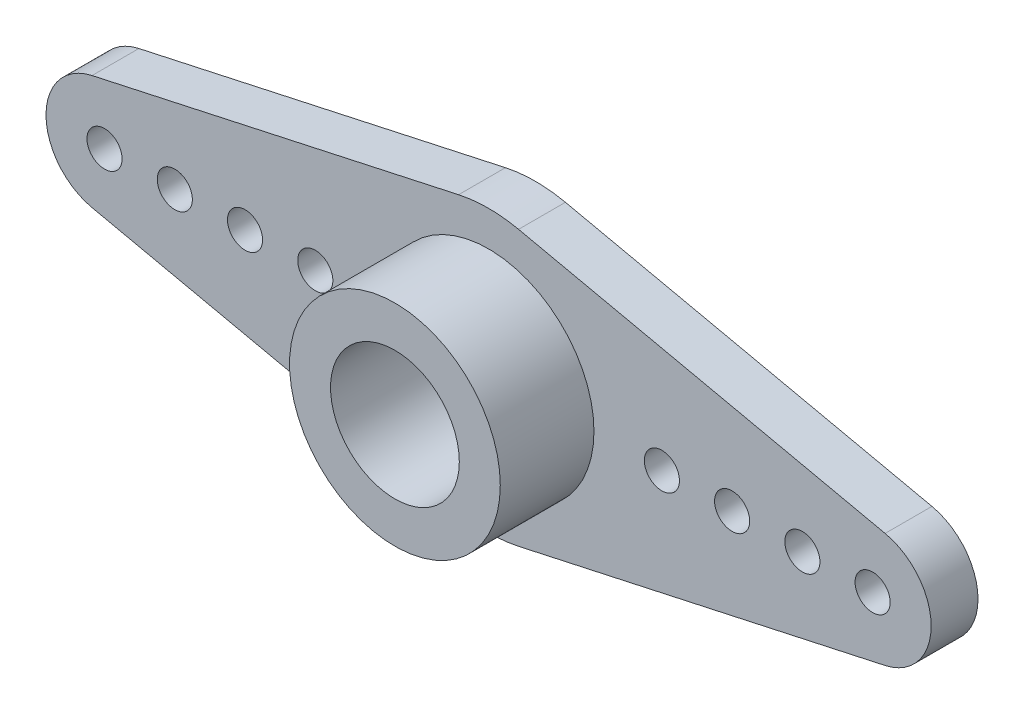
from build123d import *

# Parameters (mm, degrees)
IZIM1_R                     = 1.5
IZIM1_R_2                   = 0.75
Y_KSEKLIK_EKSTR_ZYON1_DEPTH = 2
IZIM2_R                     = 4.5
IZIM2_R_2                   = 2.75
Y_KSEKLIK_EKSTR_ZYON2_DEPTH = 4


with BuildPart() as part:
    # Çizim1 → Yükseklik-Ekstrüzyon1 (new body)
    with BuildSketch(Plane.XY):
        with BuildLine():
            Line((-16.933536585, 2.442404289), (-1.280487805, 5.861770294))
            ThreePointArc((-1.280487805, 5.861770294), (0, 6), (1.280487805, 5.861770294))
            Line((1.280487805, 5.861770294), (16.933536585, 2.442404289))
            ThreePointArc((16.933536585, 2.442404289), (18.9, 0), (16.933536585, -2.442404289))
            Line((16.933536585, -2.442404289), (1.280487805, -5.861770294))
            ThreePointArc((1.280487805, -5.861770294), (0, -6), (-1.280487805, -5.861770294))
            Line((-1.280487805, -5.861770294), (-16.933536585, -2.442404289))
            ThreePointArc((-16.933536585, -2.442404289), (-18.9, 0), (-16.933536585, 2.442404289))
        make_face()
        Circle(IZIM1_R, mode=Mode.SUBTRACT)
        with Locations((7.4, 0)):
            Circle(IZIM1_R_2, mode=Mode.SUBTRACT)
        with Locations((10.4, 0)):
            Circle(IZIM1_R_2, mode=Mode.SUBTRACT)
        with Locations((13.4, 0)):
            Circle(IZIM1_R_2, mode=Mode.SUBTRACT)
        with Locations((16.4, 0)):
            Circle(IZIM1_R_2, mode=Mode.SUBTRACT)
        with Locations((-7.4, 0)):
            Circle(IZIM1_R_2, mode=Mode.SUBTRACT)
        with Locations((-10.4, 0)):
            Circle(IZIM1_R_2, mode=Mode.SUBTRACT)
        with Locations((-13.4, 0)):
            Circle(IZIM1_R_2, mode=Mode.SUBTRACT)
        with Locations((-16.4, 0)):
            Circle(IZIM1_R_2, mode=Mode.SUBTRACT)
    extrude(amount=Y_KSEKLIK_EKSTR_ZYON1_DEPTH)

    # Çizim2 → Yükseklik-Ekstrüzyon2 (add)
    with BuildSketch(Plane.XY.offset(2)):
        Circle(IZIM2_R)
        Circle(IZIM2_R_2, mode=Mode.SUBTRACT)
    extrude(amount=Y_KSEKLIK_EKSTR_ZYON2_DEPTH)


solid = part.part
